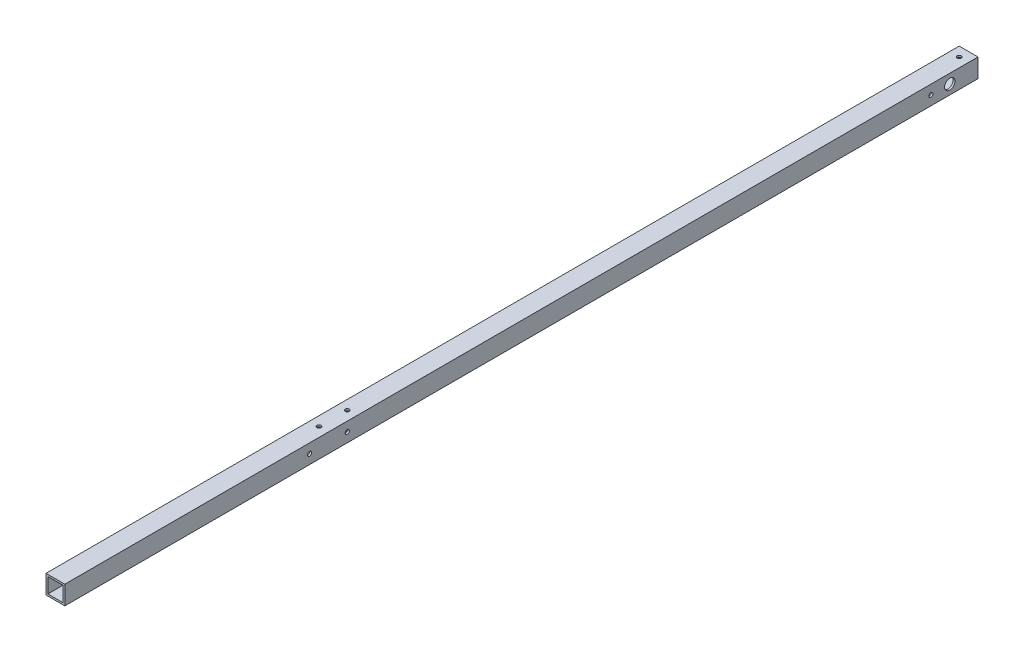
from build123d import *

# Parameters (mm, degrees)
SKETCH_1_W          = 20
SKETCH_1_H          = 20
SKETCH_1_W_2        = 16
SKETCH_1_H_2        = 16
EXTRUDE_1_DEPTH     = 970
SKETCH_2_R          = 2.2
SKETCH_2_R_2        = 5.5
CUT_EXTRUDE_1_DEPTH = 970
SKETCH_3_R          = 2.2
CUT_EXTRUDE_2_DEPTH = 970


with BuildPart() as part:
    # ｽｹｯﾁ1 → ﾎﾞｽ - 押し出し1 (new body)
    with BuildSketch(Plane.XY):
        Rectangle(SKETCH_1_W, SKETCH_1_H)
        Rectangle(SKETCH_1_W_2, SKETCH_1_H_2, mode=Mode.SUBTRACT)
    extrude(amount=EXTRUDE_1_DEPTH)

    # ｽｹｯﾁ2 → ｶｯﾄ - 押し出し1 (cut)
    with BuildSketch(Plane(origin=(10, 0, 0), x_dir=(0, 0, -1), z_dir=(1, 0, 0))):
        with Locations((-710, 0)):
            Circle(SKETCH_2_R)
        with Locations((-670, 0)):
            Circle(SKETCH_2_R)
        with Locations((-50, 0)):
            Circle(SKETCH_2_R)
        with Locations((-30, 0)):
            Circle(SKETCH_2_R_2)
    extrude(amount=-CUT_EXTRUDE_1_DEPTH, mode=Mode.SUBTRACT)

    # ｽｹｯﾁ3 → ｶｯﾄ - 押し出し2 (cut)
    with BuildSketch(Plane(origin=(0, 10, 0), x_dir=(1, 0, 0), z_dir=(0, 1, 0))):
        with Locations((0, -690)):
            Circle(SKETCH_3_R)
        with Locations((0, -660)):
            Circle(SKETCH_3_R)
        with Locations((0, -10)):
            Circle(SKETCH_3_R)
    extrude(amount=-CUT_EXTRUDE_2_DEPTH, mode=Mode.SUBTRACT)


solid = part.part
